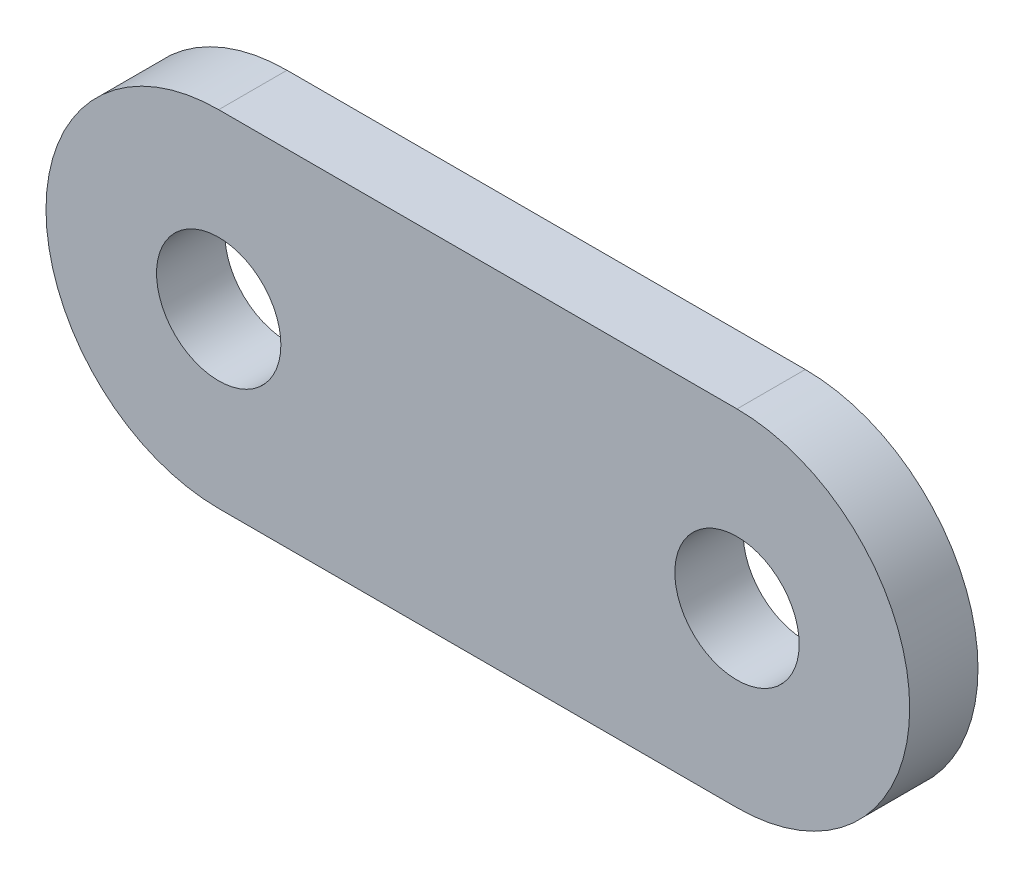
from build123d import *

# Parameters (mm, degrees)
SKETCH1_R           = 4
BOSS_EXTRUDE1_DEPTH = 4.3942


with BuildPart() as part:
    # Sketch1 → Boss-Extrude1 (new body)
    with BuildSketch(Plane.XY):
        with BuildLine():
            Line((0, 11.1125), (33.3502, 11.1125))
            ThreePointArc((33.3502, 11.1125), (44.4627, 0), (33.3502, -11.1125))
            Line((33.3502, -11.1125), (0, -11.1125))
            ThreePointArc((0, -11.1125), (-11.1125, 0), (0, 11.1125))
        make_face()
        Circle(SKETCH1_R, mode=Mode.SUBTRACT)
        with Locations((33.3502, 0)):
            Circle(SKETCH1_R, mode=Mode.SUBTRACT)
    extrude(amount=BOSS_EXTRUDE1_DEPTH)


solid = part.part
